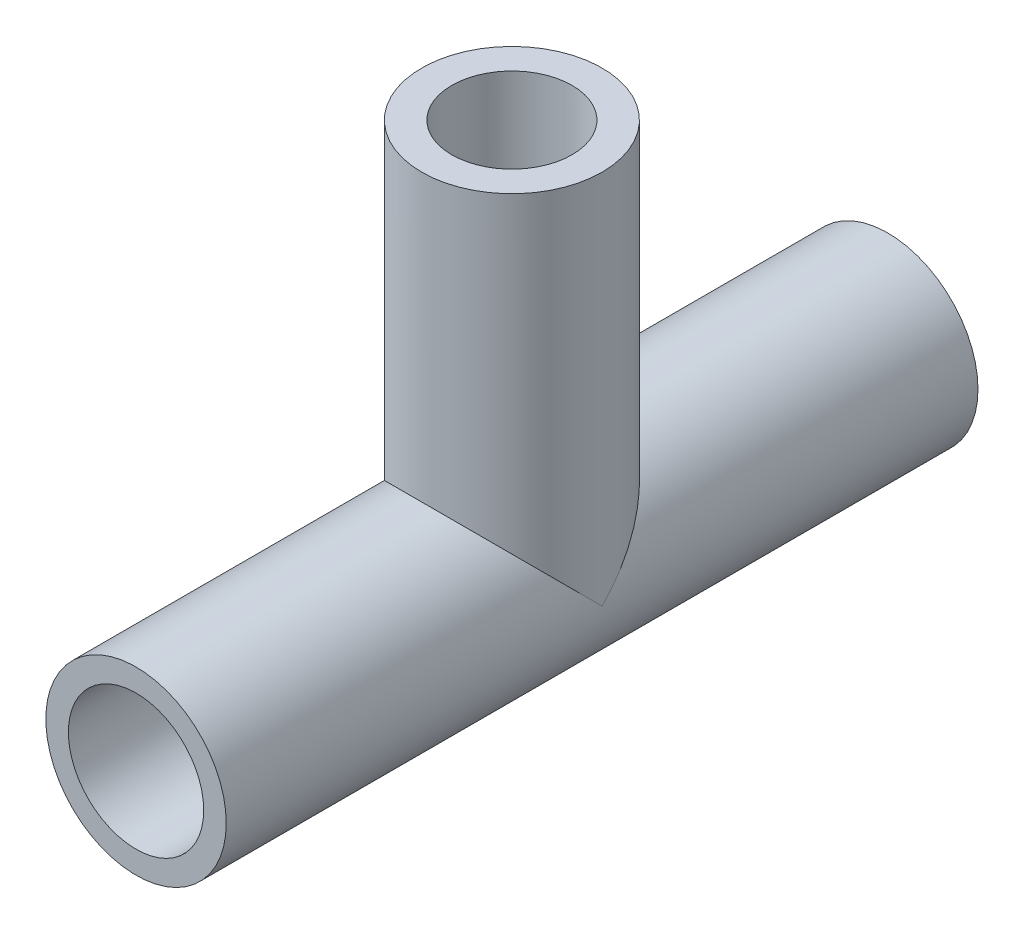
from build123d import *

# Parameters (mm, degrees)
CROQUIS1_R              = 6
CROQUIS1_R_2            = 4.5
SALIENTE_EXTRUIR1_DEPTH = 25
CROQUIS2_R              = 6
CROQUIS2_R_2            = 4
SALIENTE_EXTRUIR2_DEPTH = 25
CROQUIS3_R              = 4.5
CORTAR_EXTRUIR1_DEPTH   = 51.0000001


with BuildPart() as part:
    # Croquis1 → Saliente-Extruir1 (new body, symmetric)
    with BuildSketch(Plane.XY):
        Circle(CROQUIS1_R)
        Circle(CROQUIS1_R_2, mode=Mode.SUBTRACT)
    extrude(amount=SALIENTE_EXTRUIR1_DEPTH, both=True)

    # Croquis2 → Saliente-Extruir2 (add)
    with BuildSketch(Plane(origin=(0, 0, 0), x_dir=(1, 0, 0), z_dir=(0, 1, 0))):
        Circle(CROQUIS2_R)
        Circle(CROQUIS2_R_2, mode=Mode.SUBTRACT)
    extrude(amount=SALIENTE_EXTRUIR2_DEPTH)

    # Croquis3 → Cortar-Extruir1 (cut, through all)
    with BuildSketch(Plane.XY.offset(25)):
        Circle(CROQUIS3_R)
    extrude(amount=-CORTAR_EXTRUIR1_DEPTH, mode=Mode.SUBTRACT)


solid = part.part
